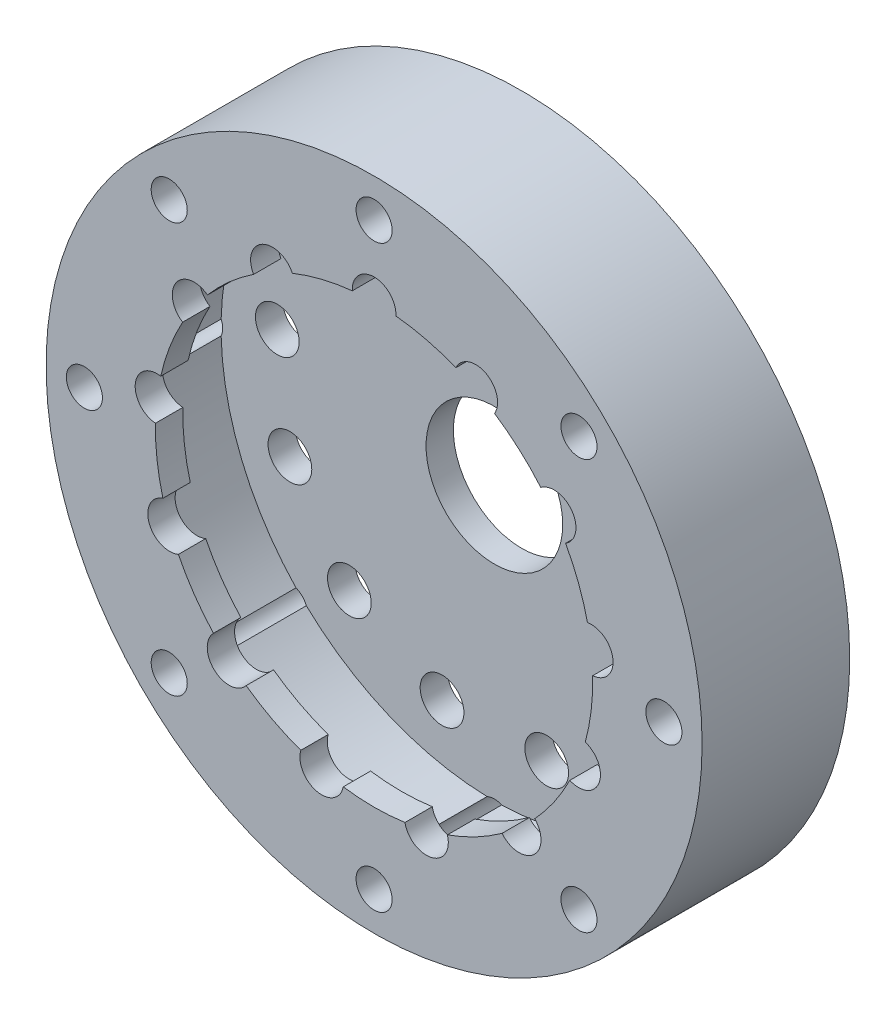
from build123d import *

# Parameters (mm, degrees)
SKETCH1_R            = 60
BOSS_EXTRUDE1_DEPTH  = 5
SKETCH2_R            = 60
SKETCH2_R_2          = 50
BOSS_EXTRUDE2_DEPTH  = 22
SKETCH3_R            = 60
SKETCH3_R_2          = 40
BOSS_EXTRUDE3_DEPTH  = 5
SKETCH4_R            = 12.5
CUT_EXTRUDE1_DEPTH   = 6
SKETCH5_R            = 4
CUT_EXTRUDE2_DEPTH   = 28
M6_CLEARANCE_HOLE1_D = 6.6


with BuildPart() as part:
    # Sketch1 → Boss-Extrude1 (new body)
    with BuildSketch(Plane.XY):
        Circle(SKETCH1_R)
    extrude(amount=BOSS_EXTRUDE1_DEPTH)

    # Sketch2 → Boss-Extrude2 (add)
    with BuildSketch(Plane.XY.offset(5)):
        Circle(SKETCH2_R)
        Circle(SKETCH2_R_2, mode=Mode.SUBTRACT)
    extrude(amount=BOSS_EXTRUDE2_DEPTH)

    # Sketch3 → Boss-Extrude3 (add)
    with BuildSketch(Plane.XY.offset(27)):
        Circle(SKETCH3_R)
        Circle(SKETCH3_R_2, mode=Mode.SUBTRACT)
    extrude(amount=-BOSS_EXTRUDE3_DEPTH)

    # Sketch4 → Cut-Extrude1 (cut, through all)
    with BuildSketch(Plane.XY.offset(5)):
        Circle(SKETCH4_R)
    extrude(amount=-CUT_EXTRUDE1_DEPTH, mode=Mode.SUBTRACT)

    # Sketch5 → Cut-Extrude2 (cut, through all)
    with BuildSketch(Plane.XY.offset(27)):
        with Locations((0, 40)):
            Circle(SKETCH5_R)
        with Locations((18.588926882, 35.418241026)):
            Circle(SKETCH5_R)
        with Locations((32.919354636, 22.722589869)):
            Circle(SKETCH5_R)
        with Locations((39.708354964, 4.82146721)):
            Circle(SKETCH5_R)
        with Locations((37.400649707, -14.184195482)):
            Circle(SKETCH5_R)
        with Locations((26.52490633, -29.940429927)):
            Circle(SKETCH5_R)
        with Locations((9.572626572, -38.837672697)):
            Circle(SKETCH5_R)
        with Locations((-9.572626572, -38.837672697)):
            Circle(SKETCH5_R)
        with Locations((-26.52490633, -29.940429927)):
            Circle(SKETCH5_R)
        with Locations((-37.400649707, -14.184195482)):
            Circle(SKETCH5_R)
        with Locations((-39.708354964, 4.82146721)):
            Circle(SKETCH5_R)
        with Locations((-32.919354636, 22.722589869)):
            Circle(SKETCH5_R)
        with Locations((-18.588926882, 35.418241026)):
            Circle(SKETCH5_R)
    extrude(amount=-CUT_EXTRUDE2_DEPTH, mode=Mode.SUBTRACT)

    # M6 Clearance Hole1 (through all)
    with Locations(Plane.XY.offset(27)):
        with Locations((0, 53), (37.476659403, 37.476659403), (53, 0), (37.476659403, -37.476659403), (0, -53), (-37.476659403, -37.476659403), (-53, 0), (-37.476659403, 37.476659403)):
            Hole(M6_CLEARANCE_HOLE1_D / 2)


solid = part.part
